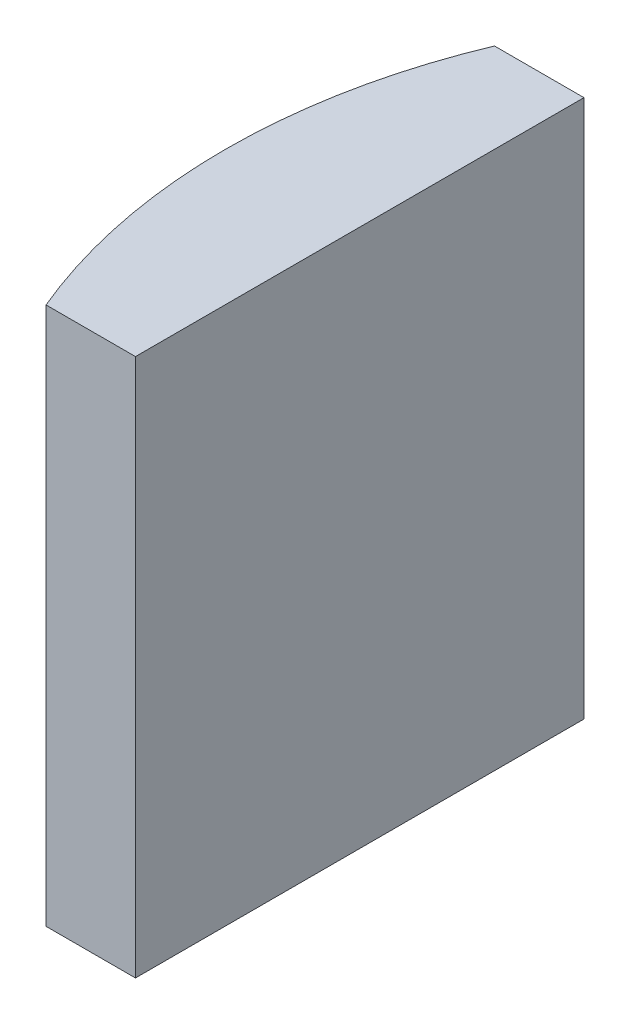
from build123d import *

# Parameters (mm, degrees)
EXTRUDE_1_DEPTH = 12


with BuildPart() as part:
    # 草图1 → 凸台-拉伸1 (new body)
    with BuildSketch(Plane(origin=(0, 0, 0), x_dir=(1, 0, 0), z_dir=(0, 1, 0))):
        with BuildLine():
            Line((-7.568926661, 5), (-5.574795665, 5))
            Line((-5.574795665, 5), (-5.574795665, -5))
            Line((-5.574795665, -5), (-7.568926661, -5))
            ThreePointArc((-7.568926661, -5), (-8.574795665, 0), (-7.568926661, 5))
        make_face()
    extrude(amount=EXTRUDE_1_DEPTH)


solid = part.part
